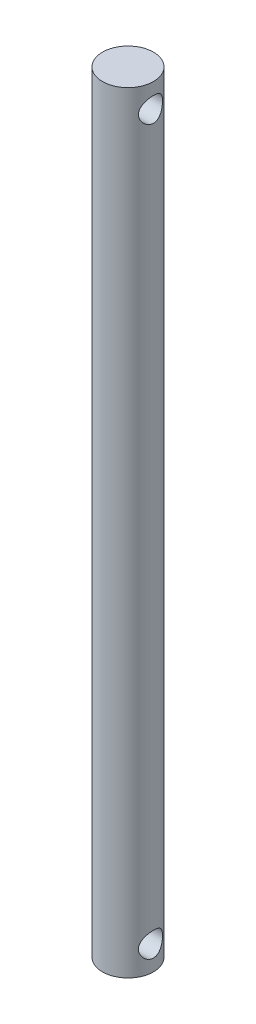
from build123d import *

# Parameters (mm, degrees)
CROQUIS1_R              = 3.175
SALIENTE_EXTRUIR1_DEPTH = 48
CROQUIS2_R              = 1.5
CORTAR_EXTRUIR1_DEPTH   = 4.175


with BuildPart() as part:
    # Croquis1 → Saliente-Extruir1 (new body, symmetric)
    with BuildSketch(Plane(origin=(0, 0, 0), x_dir=(1, 0, 0), z_dir=(0, 1, 0))):
        Circle(CROQUIS1_R)
    extrude(amount=SALIENTE_EXTRUIR1_DEPTH, both=True)

    # Croquis2 → Cortar-Extruir1 (cut, symmetric)
    with BuildSketch(Plane(origin=(0, 0, 0), x_dir=(0, 0, -1), z_dir=(1, 0, 0))):
        with Locations((0, 45)):
            Circle(CROQUIS2_R)
    cortar_extruir1 = extrude(amount=CORTAR_EXTRUIR1_DEPTH, both=True, mode=Mode.SUBTRACT)

    # Simetría3: Cortar-Extruir1 across plane
    add(cortar_extruir1.mirror(Plane.ZX), mode=Mode.SUBTRACT)


solid = part.part
